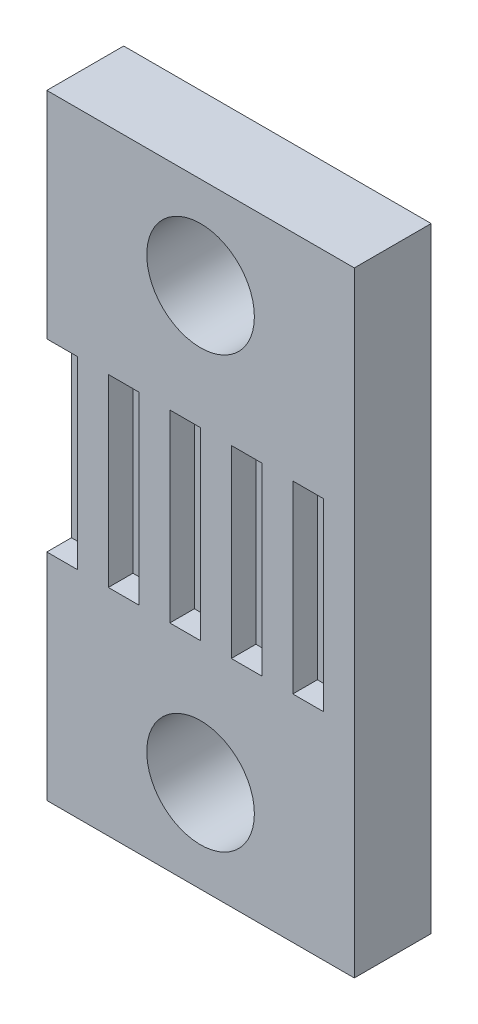
from build123d import *

# Parameters (mm, degrees)
SKETCH_1_W          = 10
SKETCH_1_H          = 20
SKETCH_1_R          = 1.75
EXTRUDE_1_DEPTH     = 2.5
SKETCH_2_W          = 1
SKETCH_2_H          = 6
CUT_EXTRUDE_1_DEPTH = 0.8


with BuildPart() as part:
    # Эскиз1 → Бобышка-Вытянуть1 (new body)
    with BuildSketch(Plane.XY):
        with Locations((5, 10)):
            Rectangle(SKETCH_1_W, SKETCH_1_H)
        with Locations((5, 17)):
            Circle(SKETCH_1_R, mode=Mode.SUBTRACT)
        with Locations((5, 3)):
            Circle(SKETCH_1_R, mode=Mode.SUBTRACT)
    extrude(amount=EXTRUDE_1_DEPTH)

    # Эскиз2 → Вырез-Вытянуть1 (cut)
    with BuildSketch(Plane.XY.offset(2.5)):
        with Locations((0.5, 10)):
            Rectangle(SKETCH_2_W, SKETCH_2_H)
        with Locations((2.5, 10)):
            Rectangle(SKETCH_2_W, SKETCH_2_H)
        with Locations((4.5, 10)):
            Rectangle(SKETCH_2_W, SKETCH_2_H)
        with Locations((6.5, 10)):
            Rectangle(SKETCH_2_W, SKETCH_2_H)
        with Locations((8.5, 10)):
            Rectangle(SKETCH_2_W, SKETCH_2_H)
    extrude(amount=-CUT_EXTRUDE_1_DEPTH, mode=Mode.SUBTRACT)


solid = part.part
